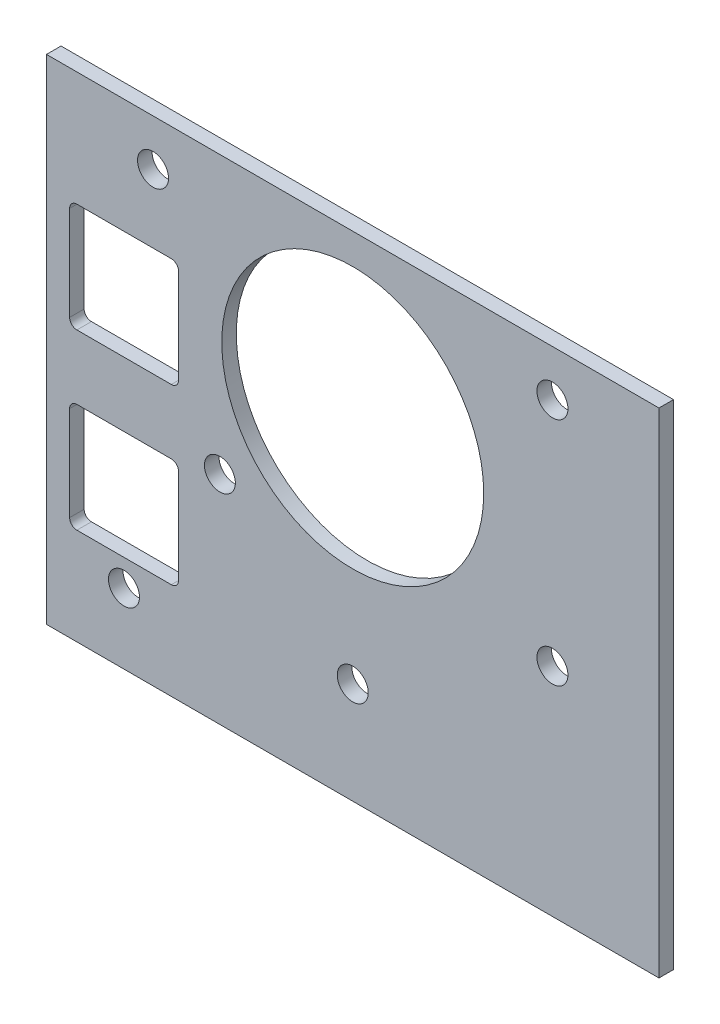
from build123d import *

# Parameters (mm, degrees)
SKETCH1_W           = 42.164
SKETCH1_H           = 33.9852
SKETCH1_R           = 9.017
SKETCH1_R_2         = 1.0668
SKETCH1_R_3         = 1.063335115
BOSS_EXTRUDE1_DEPTH = 1


with BuildPart() as part:
    # Sketch1 → Boss-Extrude1 (new body)
    with BuildSketch(Plane(origin=(0, 0, -1.017418828), x_dir=(-1, 0, 0), z_dir=(0, 0, -1))):
        with Locations((105.86640625, -147.03953125)):
            Rectangle(SKETCH1_W, SKETCH1_H)
        with Locations((105.86640625, -141.16895625)):
            Circle(SKETCH1_R, mode=Mode.SUBTRACT)
        with Locations((92.118252965, -149.10645625)):
            Circle(SKETCH1_R_2, mode=Mode.SUBTRACT)
        with Locations((92.118252965, -133.23145625)):
            Circle(SKETCH1_R_2, mode=Mode.SUBTRACT)
        with Locations((119.614559536, -133.23145625)):
            Circle(SKETCH1_R_2, mode=Mode.SUBTRACT)
        with Locations((105.86640625, -157.04395625)):
            Circle(SKETCH1_R_2, mode=Mode.SUBTRACT)
        with Locations((115.01040625, -149.10645625)):
            Circle(SKETCH1_R_3, mode=Mode.SUBTRACT)
        with Locations((121.614405679, -159.20295625)):
            Circle(SKETCH1_R_2, mode=Mode.SUBTRACT)
        with BuildLine():
            Line((118.356545978, -137.93013125), (124.856545978, -137.93013125))
            ThreePointArc((124.856545978, -137.93013125), (125.210099369, -138.07657786), (125.356545978, -138.43013125))
            Line((125.356545978, -138.43013125), (125.356545978, -144.93013125))
            ThreePointArc((125.356545978, -144.93013125), (125.210099369, -145.283684641), (124.856545978, -145.43013125))
            Line((124.856545978, -145.43013125), (118.356545978, -145.43013125))
            ThreePointArc((118.356545978, -145.43013125), (118.002992588, -145.283684641), (117.856545978, -144.93013125))
            Line((117.856545978, -144.93013125), (117.856545978, -138.43013125))
            ThreePointArc((117.856545978, -138.43013125), (118.002992588, -138.07657786), (118.356545978, -137.93013125))
        make_face(mode=Mode.SUBTRACT)
        with BuildLine():
            Line((124.856545978, -157.36813125), (118.356545978, -157.36813125))
            ThreePointArc((118.356545978, -157.36813125), (118.002992588, -157.221684641), (117.856545978, -156.86813125))
            Line((117.856545978, -156.86813125), (117.856545978, -150.36813125))
            ThreePointArc((117.856545978, -150.36813125), (118.002992588, -150.01457786), (118.356545978, -149.86813125))
            Line((118.356545978, -149.86813125), (124.856545978, -149.86813125))
            ThreePointArc((124.856545978, -149.86813125), (125.210099369, -150.01457786), (125.356545978, -150.36813125))
            Line((125.356545978, -150.36813125), (125.356545978, -156.86813125))
            ThreePointArc((125.356545978, -156.86813125), (125.210099369, -157.221684641), (124.856545978, -157.36813125))
        make_face(mode=Mode.SUBTRACT)
    extrude(amount=-BOSS_EXTRUDE1_DEPTH)


solid = part.part
